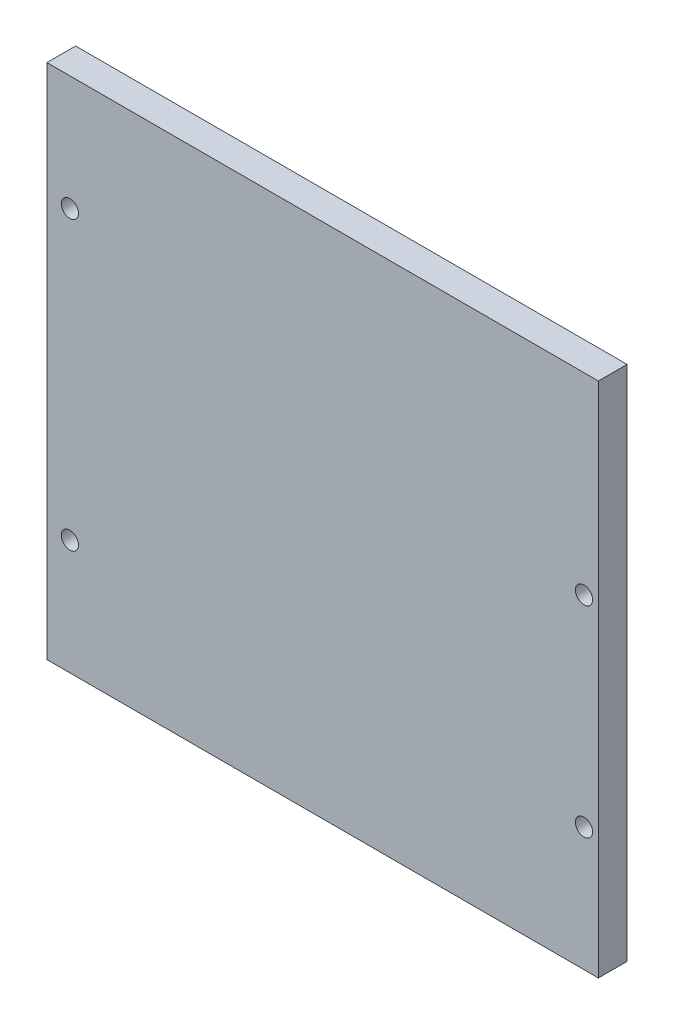
from build123d import *

# Parameters (mm, degrees)
SKETCH1_W           = 96
SKETCH1_H           = 90
BOSS_EXTRUDE1_DEPTH = 5
SKETCH2_R           = 1.5
CUT_EXTRUDE1_DEPTH  = 6
SKETCH3_R           = 1.5
CUT_EXTRUDE2_DEPTH  = 6


with BuildPart() as part:
    # Sketch1 → Boss-Extrude1 (new body)
    with BuildSketch(Plane.XY):
        Rectangle(SKETCH1_W, SKETCH1_H)
    extrude(amount=BOSS_EXTRUDE1_DEPTH)

    # Sketch2 → Cut-Extrude1 (cut, through all)
    with BuildSketch(Plane.XY.offset(5)):
        with Locations((45.5, 11.5)):
            Circle(SKETCH2_R)
        with Locations((45.5, -23.5)):
            Circle(SKETCH2_R)
    extrude(amount=-CUT_EXTRUDE1_DEPTH, mode=Mode.SUBTRACT)

    # Sketch3 → Cut-Extrude2 (cut, through all)
    with BuildSketch(Plane.XY.offset(5)):
        with Locations((-44, 25)):
            Circle(SKETCH3_R)
        with Locations((-44, -25)):
            Circle(SKETCH3_R)
    extrude(amount=-CUT_EXTRUDE2_DEPTH, mode=Mode.SUBTRACT)


solid = part.part
